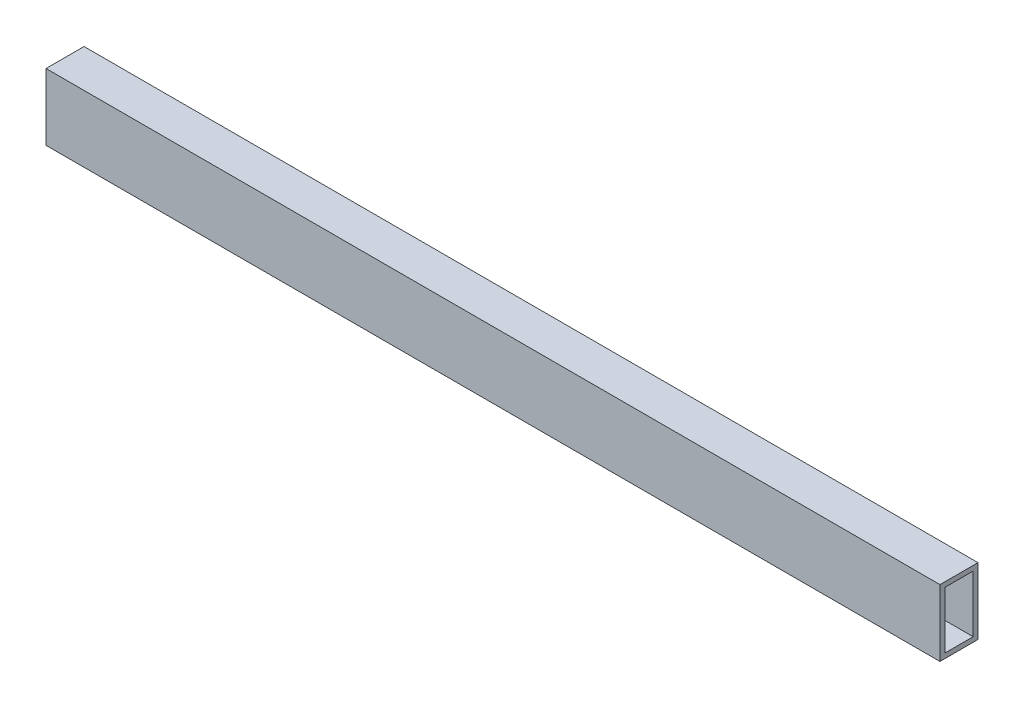
from build123d import *

# Parameters (mm, degrees)
SKETCH1_W           = 596.9
SKETCH1_H           = 44.45
BOSS_EXTRUDE1_DEPTH = 25.4
SKETCH2_W           = 18.923
SKETCH2_H           = 37.973
CUT_EXTRUDE1_DEPTH  = 599.44


with BuildPart() as part:
    # Sketch1 → Boss-Extrude1 (new body)
    with BuildSketch(Plane.XY):
        with Locations((-9171.76817789, 3136.906424003)):
            Rectangle(SKETCH1_W, SKETCH1_H)
    extrude(amount=BOSS_EXTRUDE1_DEPTH)

    # Sketch2 → Cut-Extrude1 (cut)
    with BuildSketch(Plane(origin=(-8873.31817789, 0, 0), x_dir=(0, 0, -1), z_dir=(1, 0, 0))):
        with Locations((-12.7, 3136.906424003)):
            Rectangle(SKETCH2_W, SKETCH2_H)
    extrude(amount=-CUT_EXTRUDE1_DEPTH, mode=Mode.SUBTRACT)


solid = part.part
